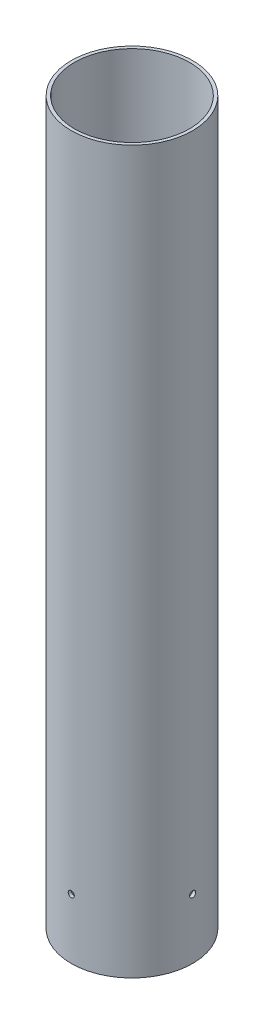
from build123d import *

# Parameters (mm, degrees)
SKETCH1_R               = 38.5
SKETCH1_R_2             = 36.5
BOSS_EXTRUDE1_DEPTH     = 457.2
SKETCH2_R               = 1.95
CUT_EXTRUDE1_DEPTH      = 39.5
CUT_EXTRUDE1_DEPTH_BACK = 39.5
SKETCH3_R               = 1.95
CUT_EXTRUDE2_DEPTH      = 39.5000001
CUT_EXTRUDE2_DEPTH_BACK = 39.5000001


with BuildPart() as part:
    # Sketch1 → Boss-Extrude1 (new body)
    with BuildSketch(Plane(origin=(0, 0, 0), x_dir=(1, 0, 0), z_dir=(0, 1, 0))):
        Circle(SKETCH1_R)
        Circle(SKETCH1_R_2, mode=Mode.SUBTRACT)
    extrude(amount=BOSS_EXTRUDE1_DEPTH)

    # Sketch2 → Cut-Extrude1 (cut, two sides)
    with BuildSketch(Plane(origin=(0, 0, 0), x_dir=(0, 0, -1), z_dir=(1, 0, 0))) as cut_extrude1_sk:
        with Locations((0, 38.1)):
            Circle(SKETCH2_R)
    extrude(amount=CUT_EXTRUDE1_DEPTH, mode=Mode.SUBTRACT)
    extrude(cut_extrude1_sk.sketch, amount=-CUT_EXTRUDE1_DEPTH_BACK, mode=Mode.SUBTRACT)

    # Sketch3 → Cut-Extrude2 (cut, two sides)
    with BuildSketch(Plane.XY) as cut_extrude2_sk:
        with Locations((0, 38.1)):
            Circle(SKETCH3_R)
    extrude(amount=CUT_EXTRUDE2_DEPTH, mode=Mode.SUBTRACT)
    extrude(cut_extrude2_sk.sketch, amount=-CUT_EXTRUDE2_DEPTH_BACK, mode=Mode.SUBTRACT)


solid = part.part
